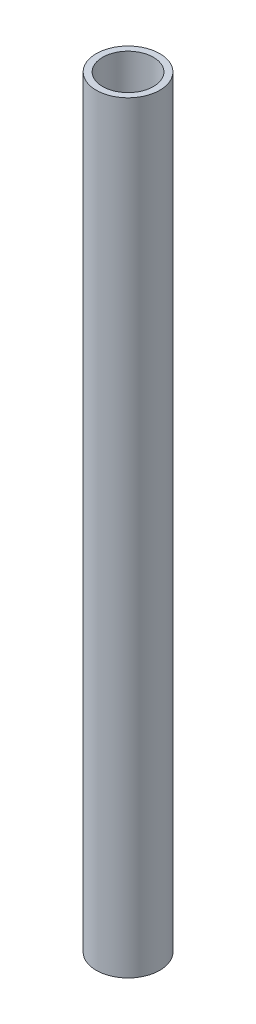
from build123d import *

# Parameters (mm, degrees)
SKETCH_1_W = 2.5
SKETCH_1_H = 300


with BuildPart() as part:
    # Эскиз1 → Повернуть1 (revolve)
    with BuildSketch(Plane.XY, mode=Mode.PRIVATE) as revolve_1_sk:
        with Locations((11.25, 82.468937605)):
            Rectangle(SKETCH_1_W, SKETCH_1_H)
    revolve(revolve_1_sk.sketch.rotate(Axis((0, 0, 0), (0, 1, 0)), 90), axis=Axis((0, 0, 0), (0, 1, 0)))  # turned: the seam where the file's is


solid = part.part
